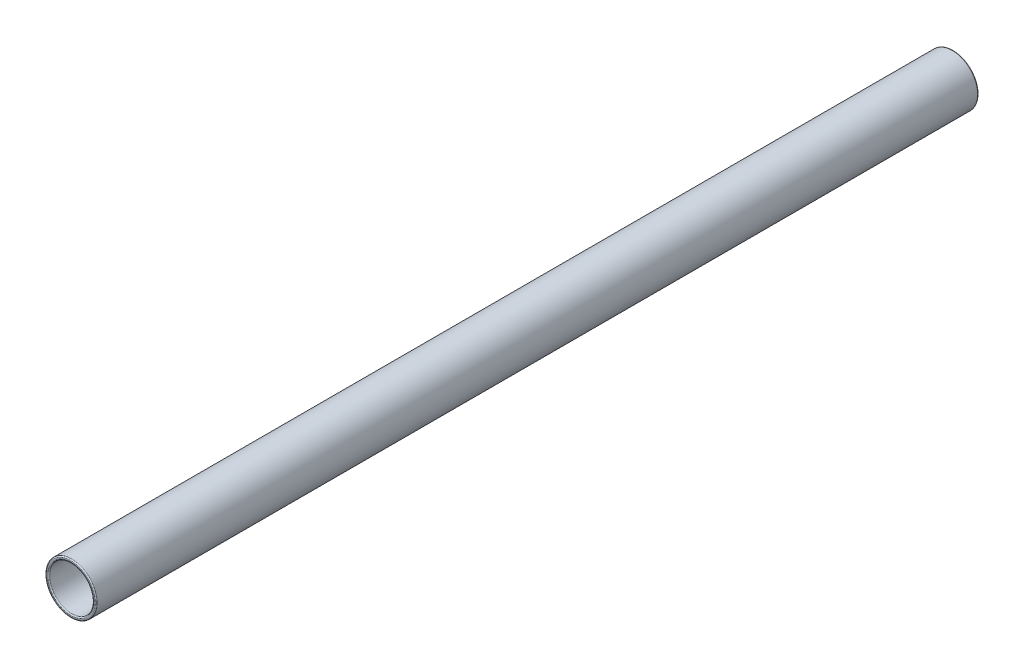
from build123d import *

# Parameters (mm, degrees)
SKETCH1_R           = 11.5
SKETCH1_R_2         = 10
BOSS_EXTRUDE1_DEPTH = 200
FILLET1_R           = 0.5


with BuildPart() as part:
    # Sketch1 → Boss-Extrude1 (new body, symmetric)
    with BuildSketch(Plane.XY):
        Circle(SKETCH1_R)
        Circle(SKETCH1_R_2, mode=Mode.SUBTRACT)
    extrude(amount=BOSS_EXTRUDE1_DEPTH, both=True)

    # Fillet1
    fillet1_edges = [part.edges().sort_by_distance(p)[0] for p in [
        (-11.5, 0, -200),
        (-11.5, 0, 200),
        (-10, 0, -200),
        (-10, 0, 200),
    ]]
    fillet(fillet1_edges, radius=FILLET1_R)


solid = part.part
